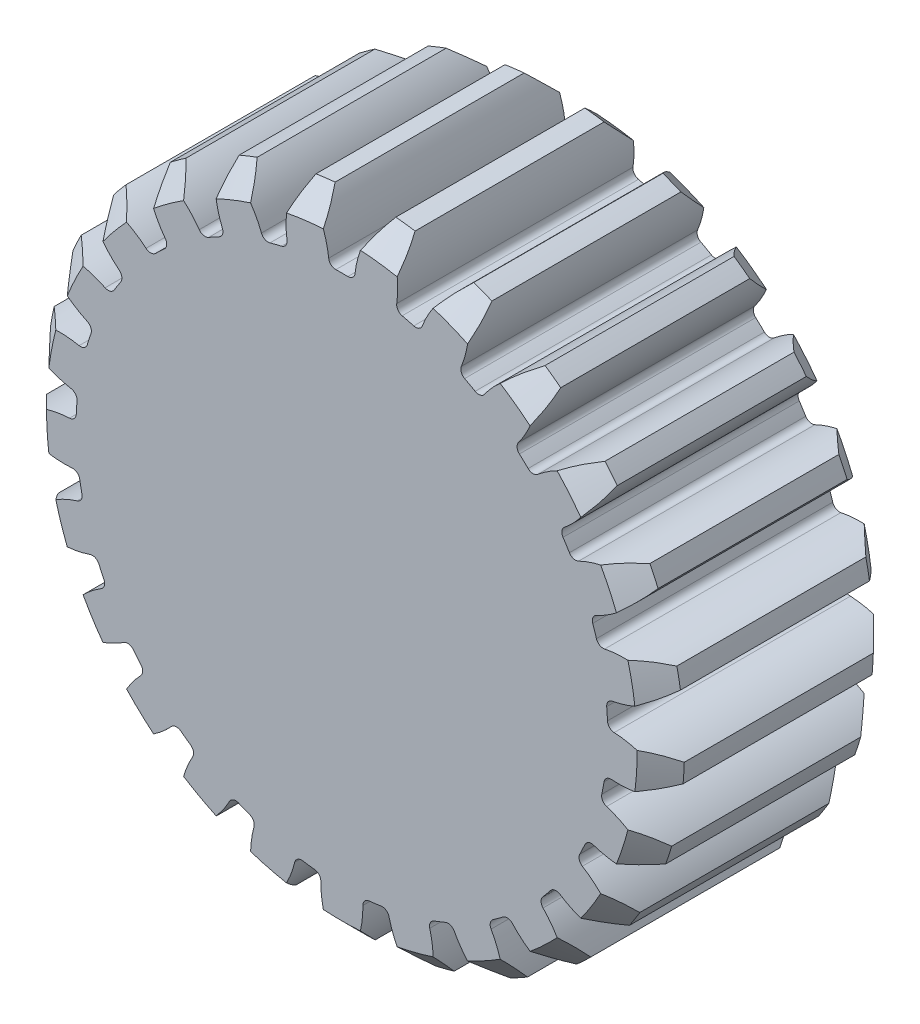
from build123d import *

# Parameters (mm, degrees)
SKETCH1_R                = 27
BOSS_EXTRUDE1_DEPTH      = 10
CUT_EXTRUDE2_DEPTH       = 20
FILLET2_R                = 0.6
CHAMFER1_SIZE            = 2
CIRPATTERN1_COUNT        = 25
FILLET2_OF_CIRPATTERN1_R = 0.6


with BuildPart() as part:
    # Sketch1 → Boss-Extrude1 (new body, symmetric)
    with BuildSketch(Plane.XY):
        Circle(SKETCH1_R)
    extrude(amount=BOSS_EXTRUDE1_DEPTH, both=True)

    # Sketch3 → Cut-Extrude2 (cut)
    with BuildSketch(Plane.XY.offset(10)):
        with BuildLine():
            ThreePointArc((-2.569085244, 26.877496182), (-1.510220721, 24.781486697), (-1.072022538, 22.474446994))
            ThreePointArc((-1.072022538, 22.474446994), (0, 22.5), (1.072022538, 22.474446994))
            ThreePointArc((1.072022538, 22.474446994), (1.510220721, 24.781486697), (2.569085244, 26.877496182))
            ThreePointArc((2.569085244, 26.877496182), (0, 27), (-2.569085244, 26.877496182))
        make_face()
    cut_extrude2 = extrude(amount=-CUT_EXTRUDE2_DEPTH, mode=Mode.SUBTRACT)

    # Fillet2
    fillet2_edges = [part.edges().sort_by_distance(p)[0] for p in [
        (-1.072022538, 22.474446994, 0),
        (1.072022538, 22.474446994, 0),
    ]]
    fillet(fillet2_edges, radius=FILLET2_R)

    # Chamfer1
    chamfer1_edges = [part.edges().sort_by_distance(p)[0] for p in [
        (0, -27, -10),
        (0, -27, 10),
    ]]
    chamfer(chamfer1_edges, length=CHAMFER1_SIZE)

    # CirPattern1: Cut-Extrude2 ×25 about axis
    cirpattern1_axis = Axis((0, 0, 0), (0, 0, 1))
    for i in range(1, CIRPATTERN1_COUNT):
        add(cut_extrude2.rotate(cirpattern1_axis, i * 360 / CIRPATTERN1_COUNT), mode=Mode.SUBTRACT)

    # Fillet2 of CirPattern1
    fillet2_of_cirpattern1_edges = [part.edges().sort_by_distance(p)[0] for p in [
        (-6.627510666, 21.50176975, 0),
        (-4.550824708, 22.034972078, 0),
        (-11.766567924, 19.178057235, 0),
        (-9.887726902, 20.210958827, 0),
        (-16.166288445, 15.649316851, 0),
        (-14.603346849, 17.117016703, 0),
        (-19.550221608, 11.137272336, 0),
        (-18.401384806, 12.947549467, 0),
        (-21.705742446, 5.92543204, 0),
        (-21.043196081, 7.964540081, 0),
        (-22.497411659, 0.341275057, 0),
        (-22.362785954, 2.481089349, 0),
        (-21.875485757, -5.264325494, 0),
        (-22.277239742, -3.158257351, 0),
        (-19.879042632, -10.539149113, 0),
        (-20.791932626, -8.599159126, 0),
        (-16.63352615, -15.151759232, 0),
        (-18.000191916, -13.499744108, 0),
        (-12.342864045, -18.812328595, 0),
        (-14.077432948, -17.552090519, 0),
        (-7.276654398, -21.290850165, 0),
        (-9.270137095, -20.501574531, 0),
        (-1.753225794, -22.431589318, 0),
        (-3.880364434, -22.162869215, 0),
        (3.880364434, -22.162869215, 0),
        (1.753225794, -22.431589318, 0),
        (9.270137095, -20.501574531, 0),
        (7.276654398, -21.290850165, 0),
        (14.077432948, -17.552090519, 0),
        (12.342864045, -18.812328595, 0),
        (18.000191916, -13.499744108, 0),
        (16.63352615, -15.151759232, 0),
        (20.791932626, -8.599159126, 0),
        (19.879042632, -10.539149113, 0),
        (22.277239742, -3.158257351, 0),
        (21.875485757, -5.264325494, 0),
        (22.362785954, 2.481089349, 0),
        (22.497411659, 0.341275057, 0),
        (21.043196081, 7.964540081, 0),
        (21.705742446, 5.92543204, 0),
        (18.401384806, 12.947549467, 0),
        (19.550221608, 11.137272336, 0),
        (14.603346849, 17.117016703, 0),
        (16.166288445, 15.649316851, 0),
        (9.887726902, 20.210958827, 0),
        (11.766567924, 19.178057235, 0),
        (4.550824708, 22.034972078, 0),
        (6.627510666, 21.50176975, 0),
    ]]
    fillet(fillet2_of_cirpattern1_edges, radius=FILLET2_OF_CIRPATTERN1_R)


solid = part.part
